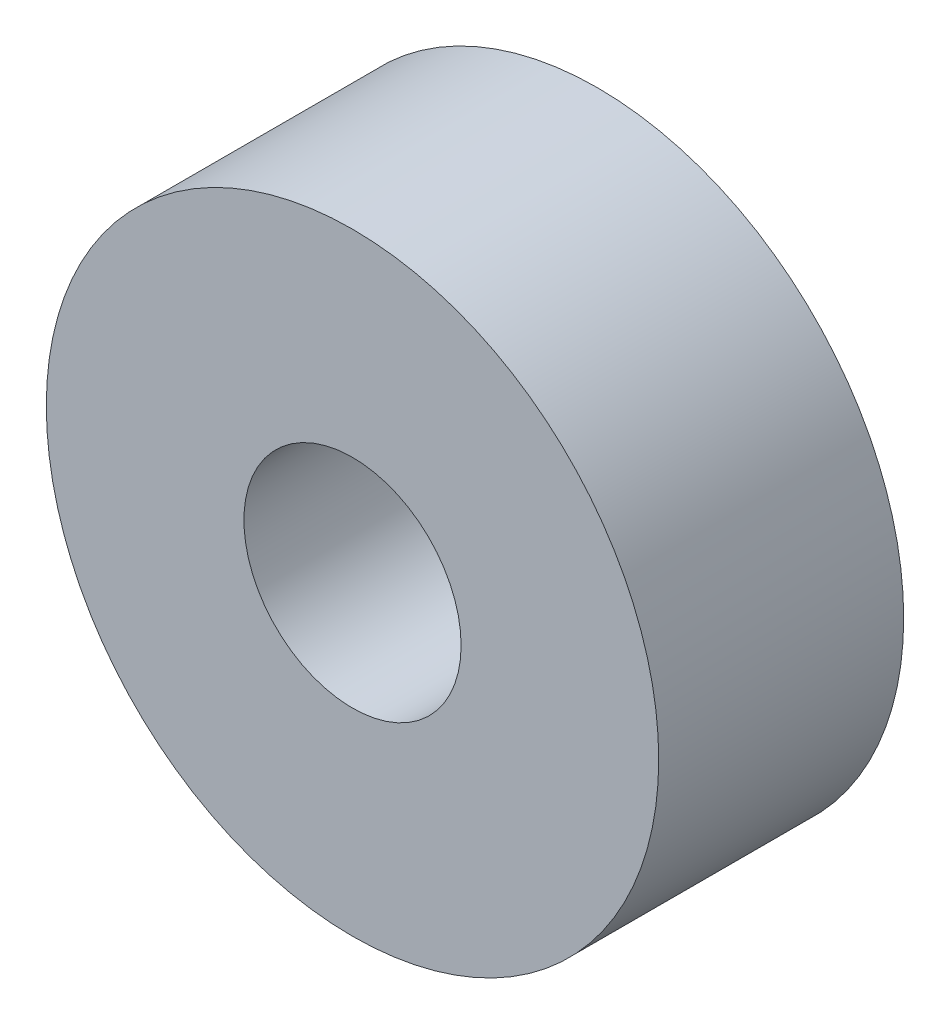
from build123d import *

# Parameters (mm, degrees)
SKETCH1_R           = 9.525
BOSS_EXTRUDE1_DEPTH = 3.81
CUT_EXTRUDE1_REACH  = 9.62
SKETCH2_R           = 3.3782


with BuildPart() as part:
    # Sketch1 → Boss-Extrude1 (new body, symmetric)
    with BuildSketch(Plane.XY):
        Circle(SKETCH1_R)
    extrude(amount=BOSS_EXTRUDE1_DEPTH, both=True)

    # Sketch2 → Cut-Extrude1 (cut, up to next)
    with BuildSketch(Plane.XY.offset(3.81), mode=Mode.PRIVATE) as cut_extrude1_sk1:
        Circle(SKETCH2_R)
    cut_extrude1_tool1 = extrude(cut_extrude1_sk1.sketch, amount=-CUT_EXTRUDE1_REACH, mode=Mode.PRIVATE) & part.part
    add(cut_extrude1_tool1.solids().sort_by_distance((0, 0, 3.81))[0], mode=Mode.SUBTRACT)


solid = part.part
